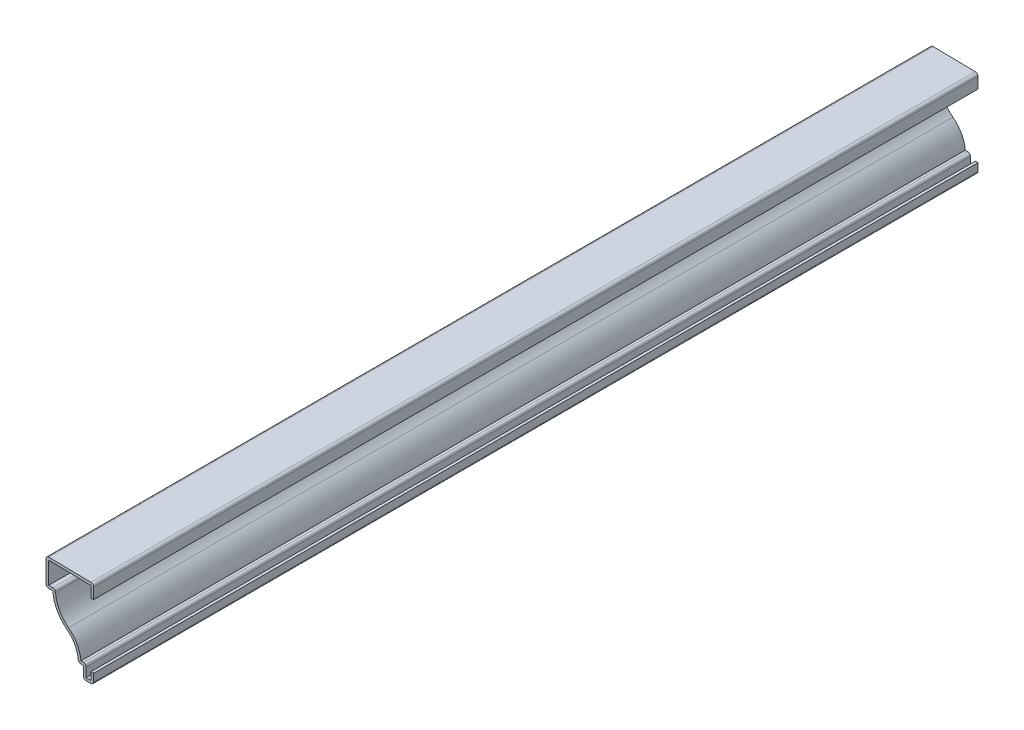
from build123d import *

# Parameters (mm, degrees)
EXTRUDE_THIN1_DEPTH = 412.75
FILLET1_R           = 1.27


with BuildPart() as part:
    # Sketch1 → Extrude-Thin1 (new body)
    with BuildSketch(Plane.XY):
        with BuildLine():
            Line((0, 4.7625), (0, 0))
            Line((0, 0), (-4.7625, 0))
            Line((-4.7625, 0), (-4.7625, 5.55625))
            Line((-4.7625, 5.55625), (-7.14375, 5.55625))
            ThreePointArc((-7.14375, 5.55625), (-8.548737384, 11.551507081), (-12.471121185, 16.298295714))
            ThreePointArc((-12.471121185, 16.298295714), (-17.097302988, 21.720310148), (-19.05, 28.575))
            Line((-19.05, 28.575), (-22.225, 28.575))
            Line((-22.225, 28.575), (-22.225, 41.275))
            Line((-22.225, 41.275), (0, 40.878125))
            Line((0, 40.878125), (0, 34.528125))
            Line((0, 34.528125), (-1.27, 34.528125))
            Line((-1.27, 34.528125), (-1.27, 39.6306011))
            Line((-1.27, 39.6306011), (-20.955, 39.982118957))
            Line((-20.955, 39.982118957), (-20.955, 29.845))
            Line((-20.955, 29.845), (-17.811850471, 29.845))
            ThreePointArc((-17.811850471, 29.845), (-16.248920172, 22.850151694), (-11.702520826, 17.309311781))
            ThreePointArc((-11.702520826, 17.309311781), (-7.705625486, 12.679096033), (-5.928475081, 6.82625))
            Line((-5.928475081, 6.82625), (-3.4925, 6.82625))
            Line((-3.4925, 6.82625), (-3.4925, 1.27))
            Line((-3.4925, 1.27), (-1.27, 1.27))
            Line((-1.27, 1.27), (-1.27, 4.7625))
            Line((-1.27, 4.7625), (0, 4.7625))
        make_face()
    extrude(amount=-EXTRUDE_THIN1_DEPTH)

    # Fillet1
    fillet1_edges = [part.edges().sort_by_distance(p)[0] for p in [
        (-17.811850471, 29.845, -206.375),
        (-3.4925, 6.82625, -206.375),
        (0, 0, -206.375),
        (-4.7625, 0, -206.375),
        (-7.14375, 5.55625, -206.375),
        (-22.225, 28.575, -206.375),
        (-22.225, 41.275, -206.375),
        (0, 40.878125, -206.375),
    ]]
    fillet(fillet1_edges, radius=FILLET1_R)


solid = part.part
